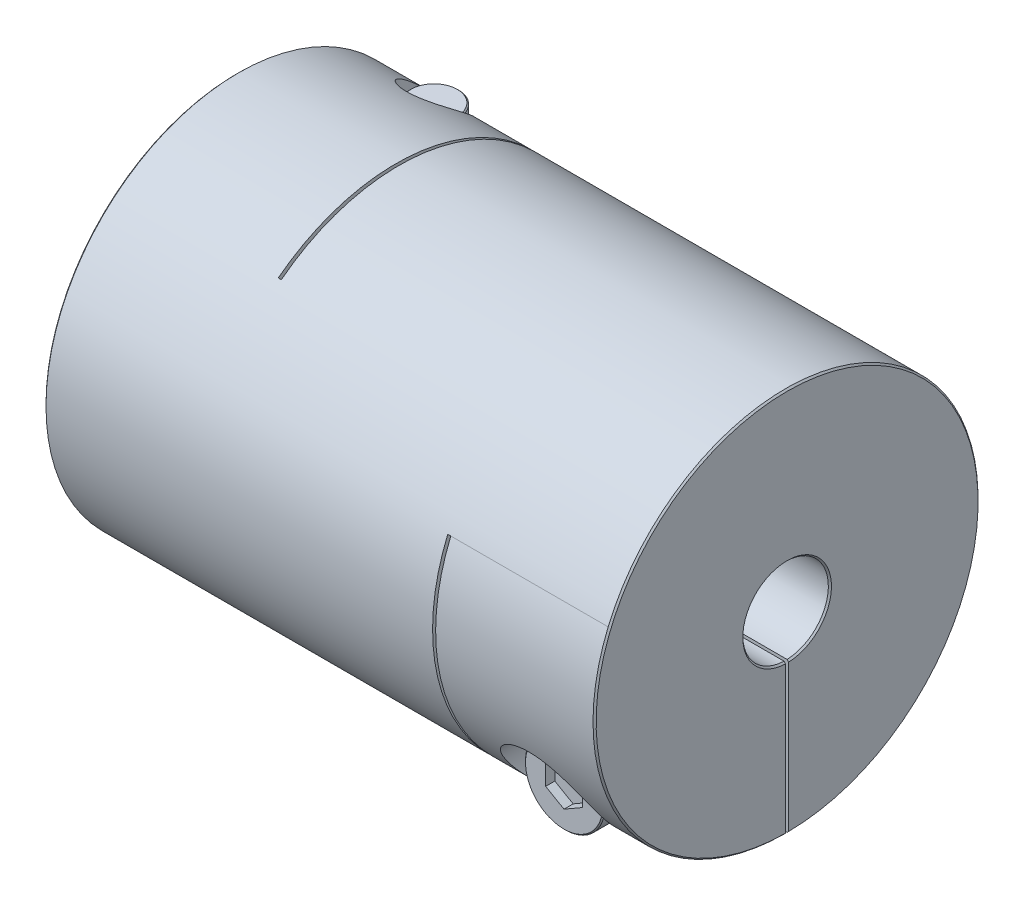
from build123d import *

# Parameters (mm, degrees)
SKETCH1_R                      = 31.5
BOSS_EXTRUDE1_DEPTH            = 45
SKETCH2_R                      = 7
CUT_EXTRUDE1_DEPTH             = 91
CHAMFER1_SIZE                  = 0.254
SKETCH4_W                      = 0.5
SKETCH4_H                      = 50.75
CUT_EXTRUDE2_DEPTH             = 64
SKETCH7_W                      = 0.5
SKETCH7_H                      = 43.75
CUT_EXTRUDE3_DEPTH             = 64
SKETCH8_W                      = 26
SKETCH8_H                      = 31.5
CUT_EXTRUDE5_DEPTH             = 0.25
SKETCH13_W                     = 26
SKETCH13_H                     = 31.5
CUT_EXTRUDE6_DEPTH             = 0.25
CBORE_FOR_M8_SHCS1_D           = 9
CBORE_FOR_M8_SHCS1_CBORE_D     = 15
CBORE_FOR_M8_SHCS1_CBORE_DEPTH = 16
CBORE_FOR_M8_SHCS2_D           = 9
CBORE_FOR_M8_SHCS2_CBORE_D     = 15
CBORE_FOR_M8_SHCS2_CBORE_DEPTH = 16
SKETCH16_R                     = 6.5
BOSS_EXTRUDE2_DEPTH            = 8
SKETCH17_R                     = 4
BOSS_EXTRUDE3_DEPTH            = 39.5
CHAMFER2_SIZE                  = 0.2
CUT_EXTRUDE7_DEPTH             = 1.5
CIRPATTERN1_COUNT              = 2
CIRPATTERN1_ANGLE              = 90


with BuildPart() as part:
    # Sketch1 → Boss-Extrude1 (new body, symmetric)
    with BuildSketch(Plane(origin=(0, 0, 0), x_dir=(0, 0, -1), z_dir=(1, 0, 0))):
        Circle(SKETCH1_R)
    extrude(amount=BOSS_EXTRUDE1_DEPTH, both=True)

    # Sketch2 → Cut-Extrude1 (cut, through all)
    with BuildSketch(Plane(origin=(45, 0, 0), x_dir=(0, 0, -1), z_dir=(1, 0, 0))):
        Circle(SKETCH2_R)
    extrude(amount=-CUT_EXTRUDE1_DEPTH, mode=Mode.SUBTRACT)

    # Chamfer1
    chamfer1_edges = [part.edges().sort_by_distance(p)[0] for p in [
        (-45, 0, 31.5),
        (45, 0, 31.5),
        (-45, 0, 7),
        (45, 0, 7),
    ]]
    chamfer(chamfer1_edges, length=CHAMFER1_SIZE)

    # Sketch4 → Cut-Extrude2 (cut, through all)
    with BuildSketch(Plane.XZ.offset(31.5)):
        with Locations((-18.75, -6.125)):
            Rectangle(SKETCH4_W, SKETCH4_H)
    extrude(amount=-CUT_EXTRUDE2_DEPTH, mode=Mode.SUBTRACT)

    # Sketch7 → Cut-Extrude3 (cut, through all)
    with BuildSketch(Plane(origin=(0, 0, -31.5), x_dir=(-1, 0, 0), z_dir=(0, 0, -1))):
        with Locations((-18.75, -9.625)):
            Rectangle(SKETCH7_W, SKETCH7_H)
    extrude(amount=-CUT_EXTRUDE3_DEPTH, mode=Mode.SUBTRACT)

    # Sketch8 → Cut-Extrude5 (cut, symmetric)
    with BuildSketch(Plane(origin=(0, 0, 0), x_dir=(1, 0, 0), z_dir=(0, 1, 0))):
        with Locations((-32, 15.75)):
            Rectangle(SKETCH8_W, SKETCH8_H)
    extrude(amount=CUT_EXTRUDE5_DEPTH, both=True, mode=Mode.SUBTRACT)

    # Sketch13 → Cut-Extrude6 (cut, symmetric)
    with BuildSketch(Plane.XY):
        with Locations((32, -15.75)):
            Rectangle(SKETCH13_W, SKETCH13_H)
    extrude(amount=CUT_EXTRUDE6_DEPTH, both=True, mode=Mode.SUBTRACT)

    # CBORE for M8 SHCS1 (through all)
    with Locations(Plane.XZ.offset(31.5)):
        with Locations((-32, -19.247271105)):
            CounterBoreHole(CBORE_FOR_M8_SHCS1_D / 2, CBORE_FOR_M8_SHCS1_CBORE_D / 2, CBORE_FOR_M8_SHCS1_CBORE_DEPTH)

    # CBORE for M8 SHCS2 (through all)
    with Locations(Plane.XY.offset(31.5)):
        with Locations((32, -19.247271105)):
            CounterBoreHole(CBORE_FOR_M8_SHCS2_D / 2, CBORE_FOR_M8_SHCS2_CBORE_D / 2, CBORE_FOR_M8_SHCS2_CBORE_DEPTH)


with BuildPart() as body_2:
    # Sketch16 → Boss-Extrude2 (new body)
    with BuildSketch(Plane.XY.offset(15.5)):
        with Locations((32, -19.247271105)):
            Circle(SKETCH16_R)
    extrude(amount=BOSS_EXTRUDE2_DEPTH)

    # Sketch17 → Boss-Extrude3 (add)
    with BuildSketch(Plane(origin=(0, 0, 15.5), x_dir=(-1, 0, 0), z_dir=(0, 0, -1))):
        with Locations(Location((-32, -19.247271105, 0), (0, 0, 180))):  # turned: the seam where the file's is
            Circle(SKETCH17_R)
    extrude(amount=BOSS_EXTRUDE3_DEPTH)

    # Chamfer2
    chamfer2_edges = [body_2.edges().sort_by_distance(p)[0] for p in [
        (25.5, -19.247271105, 15.5),
        (25.5, -19.247271105, 23.5),
        (28, -19.247271105, -24),
    ]]
    chamfer(chamfer2_edges, length=CHAMFER2_SIZE)

    # Sketch18 → Cut-Extrude7 (cut)
    with BuildSketch(Plane.XY.offset(23.5)):
        Polygon((32, -22.71137272), (35, -20.979321913), (35, -17.515220298), (32, -15.78316949), (29, -17.515220298), (29, -20.979321913), align=None)
    extrude(amount=-CUT_EXTRUDE7_DEPTH, mode=Mode.SUBTRACT)


with BuildPart() as body_3:
    # Mirror1: mirrored copy
    add(body_2.part.mirror(Plane(origin=(0, 0, 0), x_dir=(0, 0, 1), z_dir=(1, 0, 0))))


with BuildPart() as cirpattern1_1:
    # CirPattern1: pattern copy
    add(body_3.part.rotate(Axis((0, 0, 0), (1, 0, 0)), 1 * CIRPATTERN1_ANGLE / (CIRPATTERN1_COUNT - 1)))


solid = Compound([part.part, body_2.part, cirpattern1_1.part])
